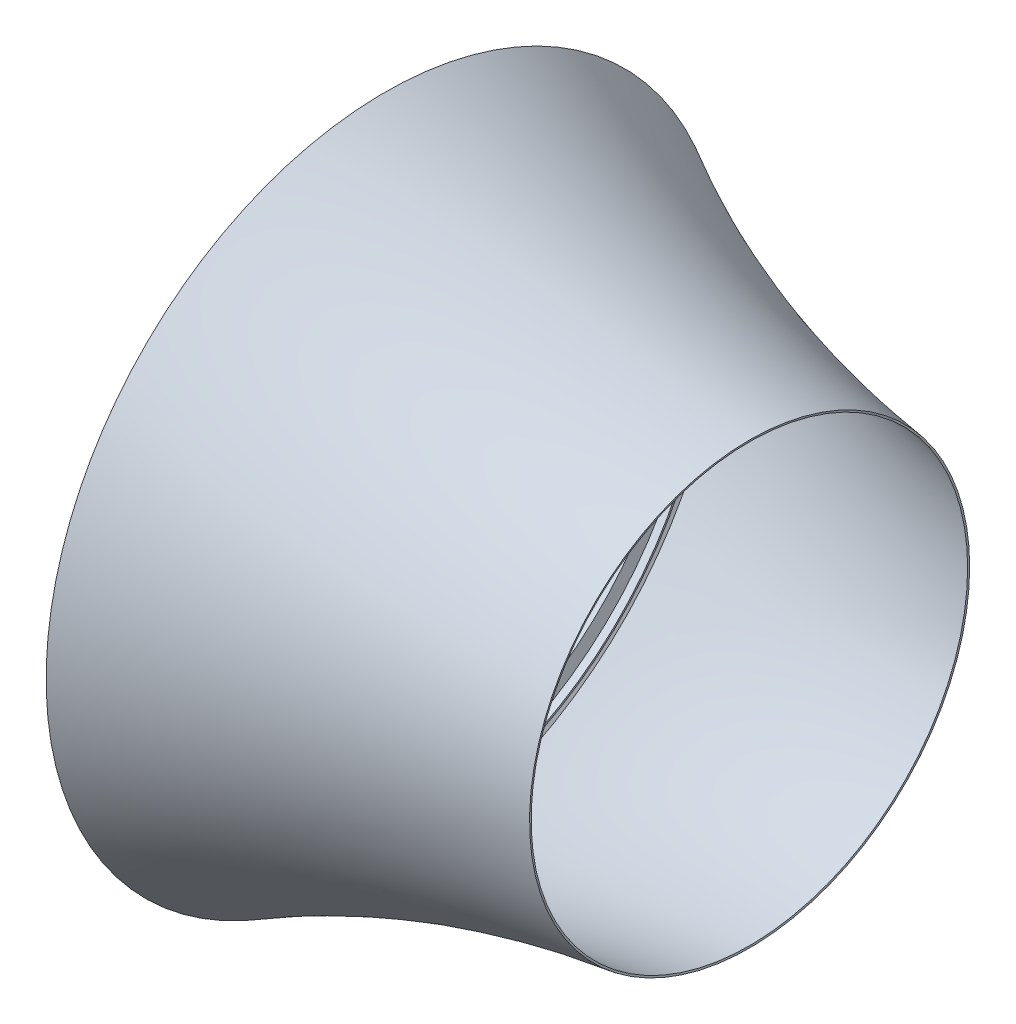
from build123d import *

# Parameters (mm, degrees)
THICKEN1_T1 = 5


with BuildPart() as body_1:
    # Surface-Revolve1: a surface, the sketch's curves turned about an axis
    with BuildLine(Plane.XY, mode=Mode.PRIVATE) as surface_revolve1_1_path:
        Line((58.164522356, 830), (33.164522356, 830))
        Line((33.164522356, 830), (25, 800))
        Line((25, 800), (0, 800))
        add(Edge.make_bspline(
            [(0, 800), (-40.64487716, 858.757553751), (0, 924.826053007)],
            knots=[0, 0, 0, 1, 1, 1], degree=2))
        add(Edge.make_bspline(
            [(0, 924.826053007), (468.319998285, 667.512309736), (1000, 600)],
            knots=[0, 0, 0, 1, 1, 1], degree=2))
    surface_revolve1_1 = Shell.revolve(surface_revolve1_1_path.wire(), 360, Axis((0, 0, 0), (1, 0, 0)))
    add(Solid.thicken(surface_revolve1_1, THICKEN1_T1))


solid = body_1.part
